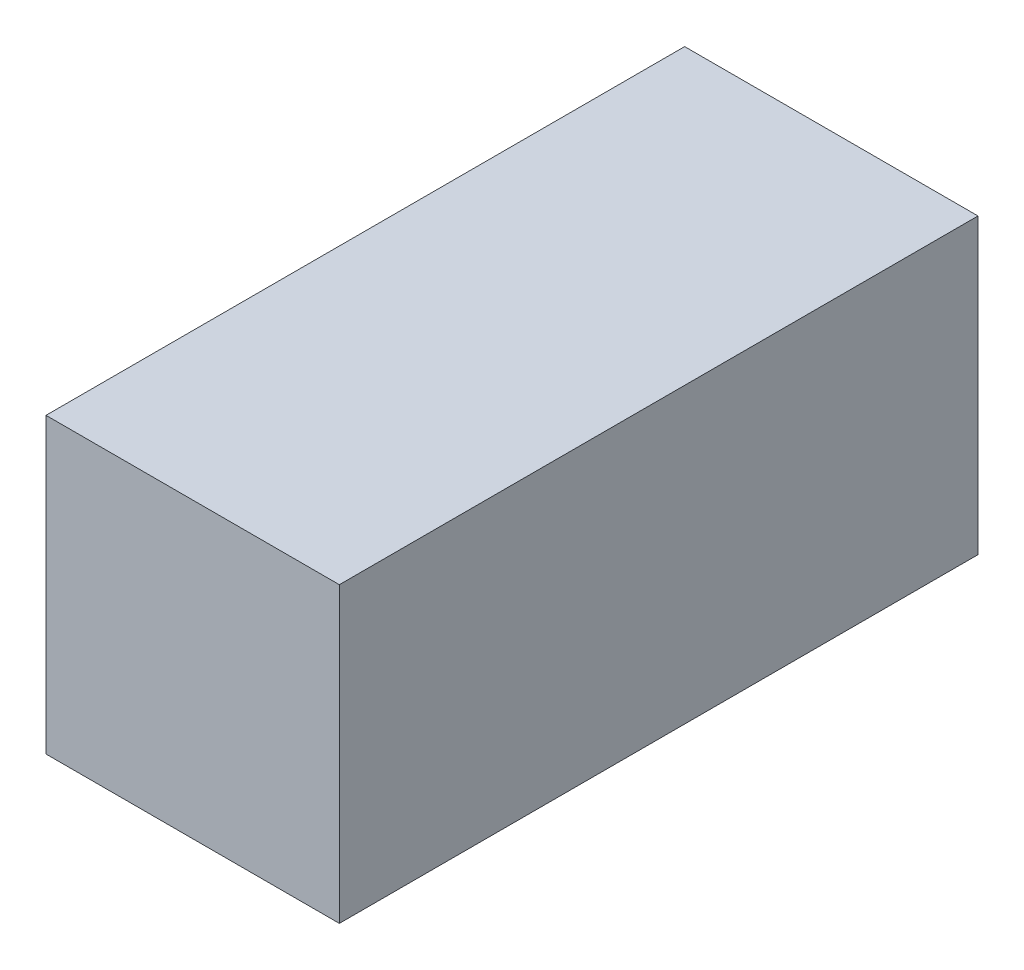
from build123d import *

# Parameters (mm, degrees)
SKETCH1_W           = 35
SKETCH1_H           = 35
BOSS_EXTRUDE1_DEPTH = 76.2


with BuildPart() as part:
    # Sketch1 → Boss-Extrude1 (new body)
    with BuildSketch(Plane.XY):
        with Locations((17.5, 17.5)):
            Rectangle(SKETCH1_W, SKETCH1_H)
    extrude(amount=BOSS_EXTRUDE1_DEPTH)


solid = part.part
